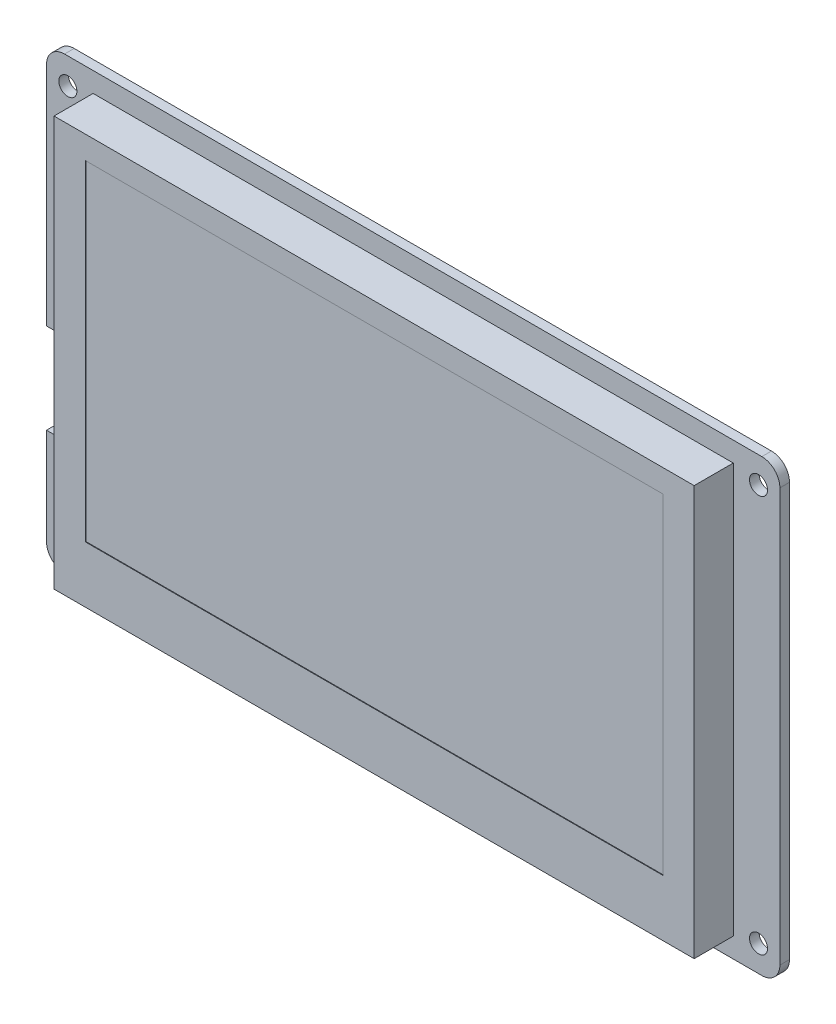
from build123d import *

# Parameters (mm, degrees)
SKETCH_1_W          = 121.9
SKETCH_1_H          = 74.7
EXTRUDE_1_DEPTH     = 1.6
SKETCH_2_R          = 1.5
CUT_EXTRUDE_1_DEPTH = 1.6
FILLET_1_R          = 3
SKETCH_3_W          = 106.4
SKETCH_3_H          = 68.1
EXTRUDE_2_DEPTH     = 6.5
SKETCH_4_W          = 96
SKETCH_4_H          = 54.9
CUT_EXTRUDE_2_DEPTH = 0.1
SKETCH_6_W          = 13.573643903
SKETCH_6_H          = 15
CUT_EXTRUDE_3_DEPTH = 9.1
SKETCH_7_R          = 5
EXTRUDE_3_DEPTH     = 5.7


with BuildPart() as part:
    # 草图1 → 凸台-拉伸1 (new body)
    with BuildSketch(Plane.XY):
        Rectangle(SKETCH_1_W, SKETCH_1_H)
    extrude(amount=EXTRUDE_1_DEPTH)

    # 草图2 → 切除-拉伸1 (cut)
    with BuildSketch(Plane.XY.offset(1.6)):
        with Locations((-57.4, 33)):
            Circle(SKETCH_2_R)
        with Locations((-57.4, -33)):
            Circle(SKETCH_2_R)
        with Locations((57.4, -33)):
            Circle(SKETCH_2_R)
        with Locations((57.4, 33)):
            Circle(SKETCH_2_R)
    extrude(amount=-CUT_EXTRUDE_1_DEPTH, mode=Mode.SUBTRACT)

    # 圆角1
    fillet_1_edges = [part.edges().sort_by_distance(p)[0] for p in [
        (60.95, -37.35, 0.8),
        (-60.95, -37.35, 0.8),
        (-60.95, 37.35, 0.8),
        (60.95, 37.35, 0.8),
    ]]
    fillet(fillet_1_edges, radius=FILLET_1_R)

    # 草图3 → 凸台-拉伸2 (add)
    with BuildSketch(Plane.XY.offset(1.6)):
        Rectangle(SKETCH_3_W, SKETCH_3_H)
    extrude(amount=EXTRUDE_2_DEPTH)

    # 草图4 → 切除-拉伸2 (cut)
    with BuildSketch(Plane.XY.offset(8.1)):
        with Locations((0, 2.8)):
            Rectangle(SKETCH_4_W, SKETCH_4_H)
    extrude(amount=-CUT_EXTRUDE_2_DEPTH, mode=Mode.SUBTRACT)

    # 草图6 → 切除-拉伸3 (cut, through all)
    with BuildSketch(Plane(origin=(0, 0, 0), x_dir=(-1, 0, 0), z_dir=(0, 0, -1))):
        with Locations((63.536821952, -10.8)):
            Rectangle(SKETCH_6_W, SKETCH_6_H)
    extrude(amount=-CUT_EXTRUDE_3_DEPTH, mode=Mode.SUBTRACT)

    # 草图7 → 凸台-拉伸3 (add)
    with BuildSketch(Plane(origin=(0, 0, 0), x_dir=(-1, 0, 0), z_dir=(0, 0, -1))):
        with Locations((40.95, 25.35)):
            Circle(SKETCH_7_R)
    extrude(amount=EXTRUDE_3_DEPTH)


solid = part.part
